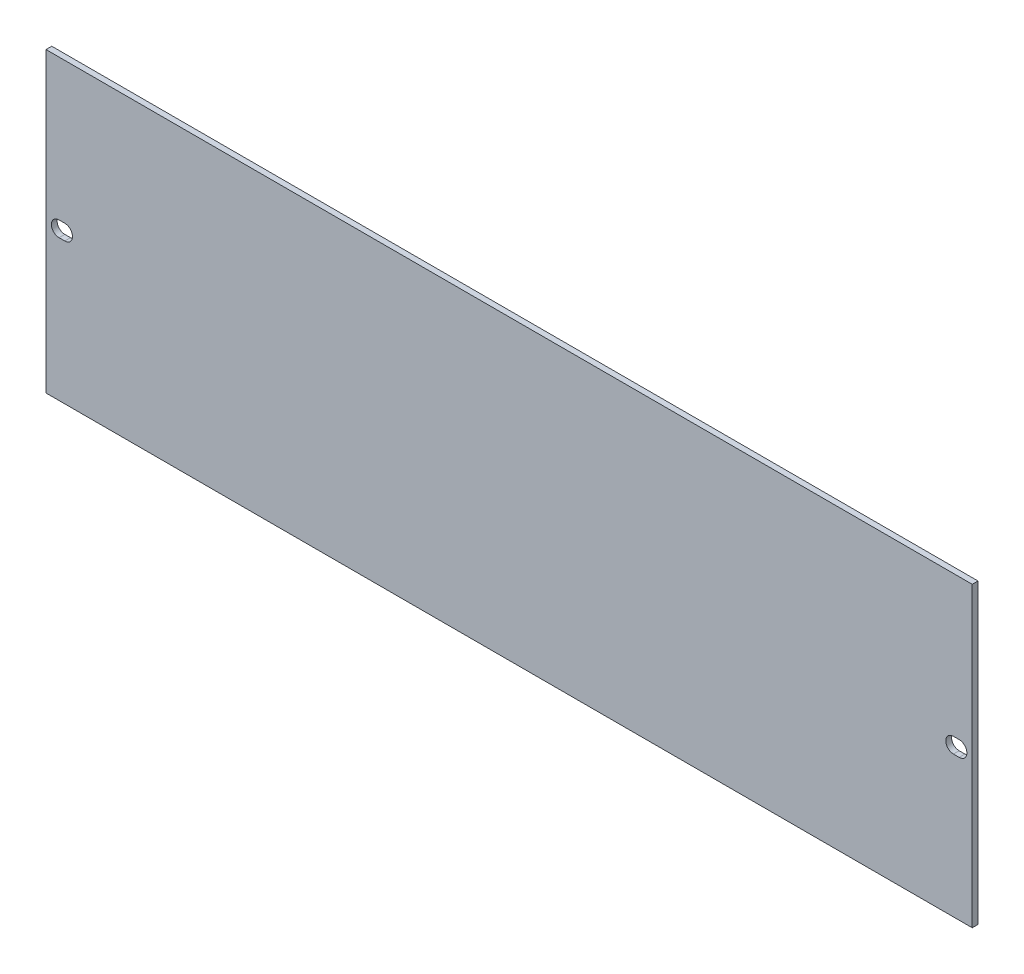
from build123d import *

# Parameters (mm, degrees)
CROQUIS1_W              = 482.6
CROQUIS1_H              = 155
SALIENTE_EXTRUIR1_DEPTH = 3


with BuildPart() as part:
    # Croquis1 → Saliente-Extruir1 (new body)
    with BuildSketch(Plane.XY):
        Rectangle(CROQUIS1_W, CROQUIS1_H)
        with BuildLine():
            Line((-234.5, 4), (-231.5, 4))
            ThreePointArc((-231.5, 4), (-227.5, 0), (-231.5, -4))
            Line((-231.5, -4), (-234.5, -4))
            ThreePointArc((-234.5, -4), (-238.5, 0), (-234.5, 4))
        make_face(mode=Mode.SUBTRACT)
        with BuildLine():
            Line((234.5, 4), (231.5, 4))
            ThreePointArc((231.5, 4), (227.5, 0), (231.5, -4))
            Line((231.5, -4), (234.5, -4))
            ThreePointArc((234.5, -4), (238.5, 0), (234.5, 4))
        make_face(mode=Mode.SUBTRACT)
    extrude(amount=SALIENTE_EXTRUIR1_DEPTH)


solid = part.part
